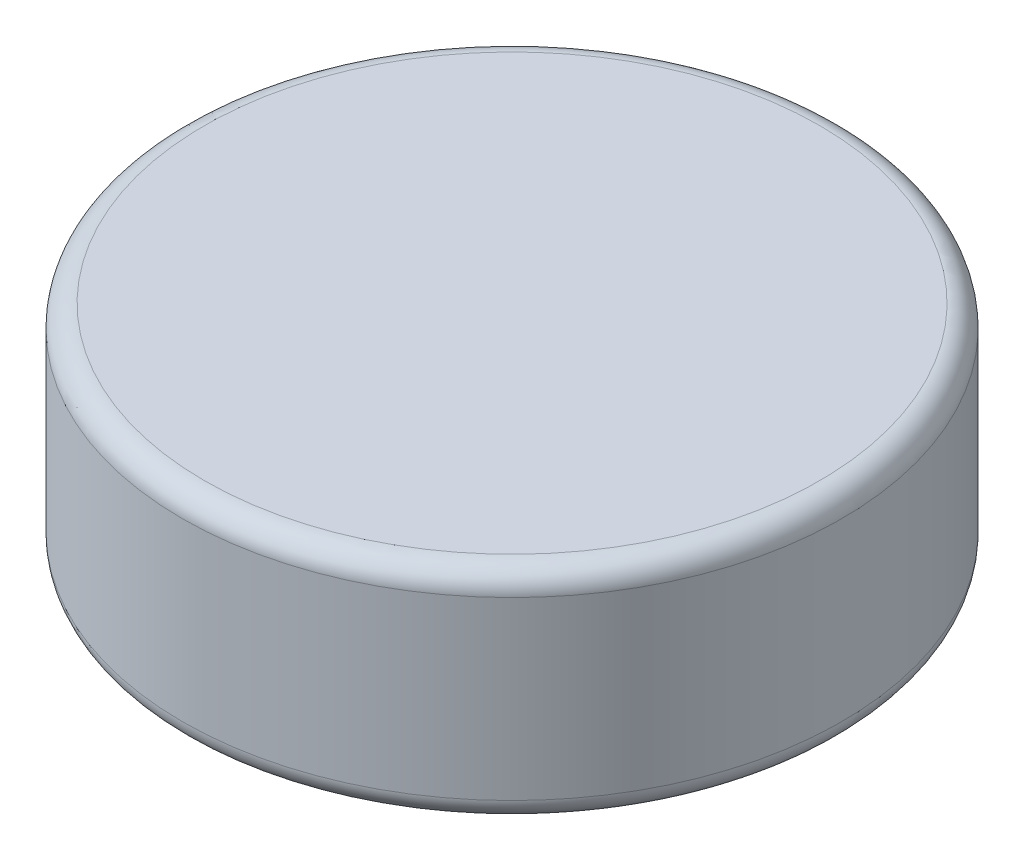
from build123d import *

# Parameters (mm, degrees)
SKETCH_1_R      = 3
EXTRUDE_1_DEPTH = 2
FILLET_1_R      = 0.2


with BuildPart() as part:
    # 草图1 → 凸台-拉伸1 (new body)
    with BuildSketch(Plane(origin=(0, 0, 0), x_dir=(1, 0, 0), z_dir=(0, 1, 0))):
        Circle(SKETCH_1_R)
    extrude(amount=EXTRUDE_1_DEPTH)

    # 圆角1
    fillet_1_edges = [part.edges().sort_by_distance(p)[0] for p in [
        (-3, 0, 0),
        (-3, 2, 0),
    ]]
    fillet(fillet_1_edges, radius=FILLET_1_R)


solid = part.part
